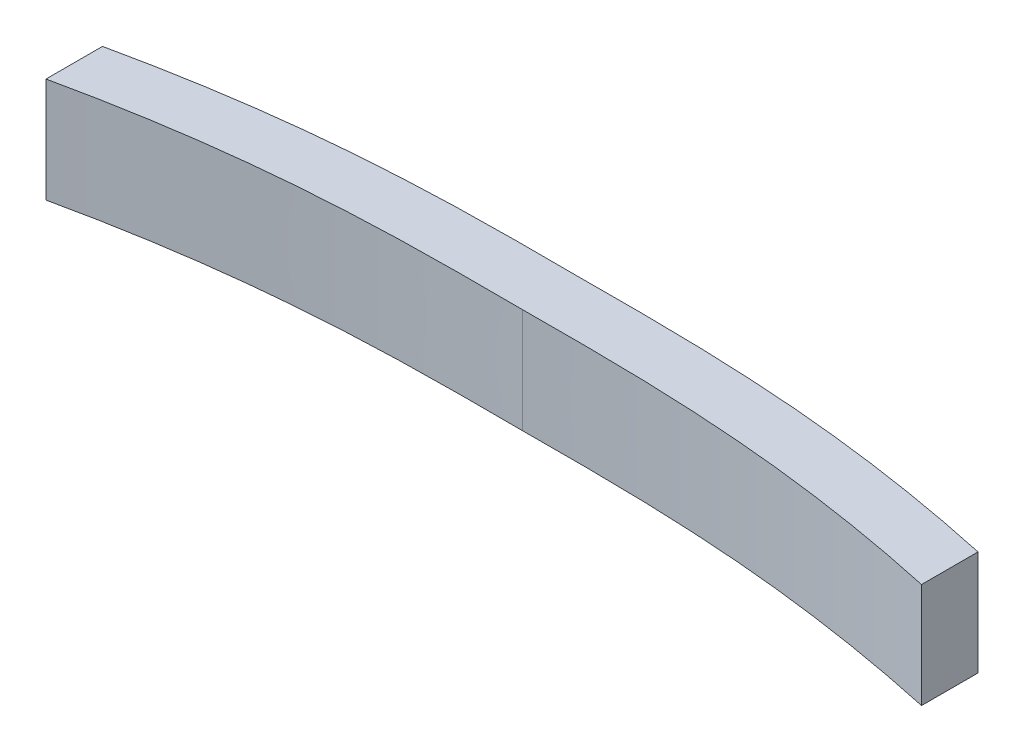
from build123d import *

# Parameters (mm, degrees)
BOSS_EXTRUDE1_DEPTH     = 14
CUT_EXTRUDE1_START      = -1
CUT_EXTRUDE1_DEPTH      = 12
SKETCH5_R               = 2
CUT_EXTRUDE2_DEPTH      = 10
SKETCH6_W               = 117.319125092
SKETCH6_H               = 10.762389646
CUT_EXTRUDE3_DEPTH      = 61.267639965
CUT_EXTRUDE3_DEPTH_BACK = 61.267639965


with BuildPart() as part:
    # Sketch1 → Boss-Extrude1 (new body)
    with BuildSketch(Plane(origin=(0, 0, 0), x_dir=(1, 0, 0), z_dir=(0, 1, 0))):
        with BuildLine():
            Line((-56.7108806, 8.042770274), (-56.7108806, 6.805307476))
            Line((-56.7108806, 6.805307476), (-32.823491302, 6.805307476))
            add(Edge.make_bspline(
                [(-32.823491302, 6.805307476), (-32.296255898, 6.856181615), (-26.989208291, 7.346453988), (-16.87934757, 7.860332352), (-7.605819721, 7.844934175), (-2.44151388, 7.817702683)],
                knots=[0.442922252, 0.442922252, 0.442922252, 0.442922252, 0.47203113, 0.735860593, 1, 1, 1, 1], degree=3))
            add(Edge.make_bspline(
                [(27.940463543, 6.805307476), (27.413228139, 6.856181615), (22.106180532, 7.346453988), (11.99631981, 7.860332352), (2.722791962, 7.844934175), (-2.44151388, 7.817702683)],
                knots=[0.442922252, 0.442922252, 0.442922252, 0.442922252, 0.47203113, 0.735860593, 1, 1, 1, 1], degree=3))
            Line((27.940463543, 6.805307476), (51.827852841, 6.805307476))
            Line((51.827852841, 6.805307476), (51.827852841, 8.042770274))
            add(Edge.make_bspline(
                [(51.827852841, 8.042770274), (43.440678216, 9.870534091), (30.144344491, 11.93787877), (11.99631981, 12.860332352), (2.722791962, 12.844934175), (-2.44151388, 12.817702683)],
                knots=[0, 0, 0, 0, 0.47203113, 0.735860593, 1, 1, 1, 1], degree=3))
            add(Edge.make_bspline(
                [(-56.7108806, 8.042770274), (-48.323705975, 9.870534091), (-35.02737225, 11.93787877), (-16.87934757, 12.860332352), (-7.605819721, 12.844934175), (-2.44151388, 12.817702683)],
                knots=[0, 0, 0, 0, 0.47203113, 0.735860593, 1, 1, 1, 1], degree=3))
        make_face()
        with BuildLine():
            Line((-32.823491302, 6.805307476), (-56.7108806, 6.805307476))
            Line((-56.7108806, 6.805307476), (-56.7108806, 3.042770274))
            add(Edge.make_bspline(
                [(-56.7108806, 3.042770274), (-48.840920262, 4.757820859), (-40.845933501, 6.031203848), (-32.823491302, 6.805307476)],
                knots=[0, 0, 0, 0, 0.442922252, 0.442922252, 0.442922252, 0.442922252], degree=3))
        make_face()
        with BuildLine():
            Line((-56.7108806, 10.042770274), (-56.7108806, 8.042770274))
            add(Edge.make_bspline(
                [(-56.7108806, 8.042770274), (-48.323705975, 9.870534091), (-35.02737225, 11.93787877), (-16.87934757, 12.860332352), (-7.605819721, 12.844934175), (-2.44151388, 12.817702683)],
                knots=[0, 0, 0, 0, 0.47203113, 0.735860593, 1, 1, 1, 1], degree=3))
            add(Edge.make_bspline(
                [(51.827852841, 8.042770274), (43.440678216, 9.870534091), (30.144344491, 11.93787877), (11.99631981, 12.860332352), (2.722791962, 12.844934175), (-2.44151388, 12.817702683)],
                knots=[0, 0, 0, 0, 0.47203113, 0.735860593, 1, 1, 1, 1], degree=3))
            Line((51.827852841, 8.042770274), (51.827852841, 10.042770274))
            add(Edge.make_bspline(
                [(51.827852841, 10.042770274), (43.440678216, 11.870534091), (30.144344491, 13.93787877), (11.99631981, 14.860332352), (2.722791962, 14.844934175), (-2.44151388, 14.817702683)],
                knots=[0, 0, 0, 0, 0.47203113, 0.735860593, 1, 1, 1, 1], degree=3))
            add(Edge.make_bspline(
                [(-56.7108806, 10.042770274), (-48.323705975, 11.870534091), (-35.02737225, 13.93787877), (-16.87934757, 14.860332352), (-7.605819721, 14.844934175), (-2.44151388, 14.817702683)],
                knots=[0, 0, 0, 0, 0.47203113, 0.735860593, 1, 1, 1, 1], degree=3))
        make_face()
        with BuildLine():
            Line((51.827852841, 6.805307476), (27.940463543, 6.805307476))
            add(Edge.make_bspline(
                [(51.827852841, 3.042770274), (43.957892503, 4.757820859), (35.962905742, 6.031203848), (27.940463543, 6.805307476)],
                knots=[0, 0, 0, 0, 0.442922252, 0.442922252, 0.442922252, 0.442922252], degree=3))
            Line((51.827852841, 3.042770274), (51.827852841, 6.805307476))
        make_face()
    extrude(amount=BOSS_EXTRUDE1_DEPTH)

    # Sketch2 → Cut-Extrude1 (cut)
    with BuildSketch(Plane(origin=(0, 14, 0), x_dir=(1, 0, 0), z_dir=(0, 1, 0)).offset(CUT_EXTRUDE1_START)):
        with BuildLine():
            Line((-55.7108806, 10.258170898), (-55.7108806, 4.258086623))
            add(Edge.make_bspline(
                [(-55.7108806, 4.258086623), (-50.342859001, 5.400468361), (-41.88238795, 6.862517021), (-30.478251076, 8.08618105), (-21.960755969, 8.606039162), (-12.680255084, 8.866102662), (-2.488255396, 8.788816201), (7.839601208, 8.866738732), (17.143204354, 8.604590131), (25.594666904, 8.081695492), (36.910484771, 6.875367198), (45.349986498, 5.423872017), (50.827852841, 4.258091684)],
                knots=[0.009365711, 0.009365711, 0.009365711, 0.009365711, 0.160113822, 0.245011966, 0.32430349, 0.394459254, 0.499999871, 0.60425614, 0.678146052, 0.755618705, 0.836798939, 0.990634118, 0.990634118, 0.990634118, 0.990634118], degree=3))
            Line((50.827852841, 4.258091684), (50.827852841, 10.258170898))
            add(Edge.make_bspline(
                [(50.827852841, 10.258170898), (42.763137338, 11.97497257), (29.804113131, 13.955172533), (11.99631981, 14.860332352), (2.722791962, 14.844934175), (-2.44151388, 14.817702683)],
                knots=[0.01874757, 0.01874757, 0.01874757, 0.01874757, 0.47203113, 0.735860593, 1, 1, 1, 1], degree=3))
            add(Edge.make_bspline(
                [(-2.44151388, 14.817702683), (-7.605819721, 14.844934175), (-16.87934757, 14.860332352), (-34.68714089, 13.955172533), (-47.646165097, 11.97497257), (-55.7108806, 10.258170898)],
                knots=[0, 0, 0, 0, 0.264139407, 0.52796887, 0.98125243, 0.98125243, 0.98125243, 0.98125243], degree=3))
        make_face()
        with BuildLine():
            Line((-2.44151388, 17.910861514), (-2.44151388, 14.817702683))
            add(Edge.make_bspline(
                [(50.827852841, 10.258170898), (42.763137338, 11.97497257), (29.804113131, 13.955172533), (11.99631981, 14.860332352), (2.722791962, 14.844934175), (-2.44151388, 14.817702683)],
                knots=[0.01874757, 0.01874757, 0.01874757, 0.01874757, 0.47203113, 0.735860593, 1, 1, 1, 1], degree=3))
            Line((50.827852841, 10.258170898), (50.827852841, 19.353755181))
            Line((50.827852841, 19.353755181), (-2.44151388, 17.910861514))
        make_face()
        with BuildLine():
            Line((-55.7108806, 16.467967847), (-55.7108806, 10.258170898))
            add(Edge.make_bspline(
                [(-2.44151388, 14.817702683), (-7.605819721, 14.844934175), (-16.87934757, 14.860332352), (-34.68714089, 13.955172533), (-47.646165097, 11.97497257), (-55.7108806, 10.258170898)],
                knots=[0, 0, 0, 0, 0.264139407, 0.52796887, 0.98125243, 0.98125243, 0.98125243, 0.98125243], degree=3))
            Line((-2.44151388, 14.817702683), (-2.44151388, 17.910861514))
            Line((-2.44151388, 17.910861514), (-55.7108806, 16.467967847))
        make_face()
    extrude(amount=-CUT_EXTRUDE1_DEPTH, mode=Mode.SUBTRACT)

    # Sketch5 → Cut-Extrude2 (cut)
    with BuildSketch(Plane(origin=(0, 1, 0), x_dir=(1, 0, 0), z_dir=(0, 1, 0))):
        with Locations((-2.44151388, 14.817702683)):
            Circle(SKETCH5_R)
    extrude(amount=-CUT_EXTRUDE2_DEPTH, mode=Mode.SUBTRACT)

    # Sketch6 → Cut-Extrude3 (cut, two sides)
    with BuildSketch(Plane.XY) as cut_extrude3_sk:
        with Locations((-0.730172647, -4.381194823)):
            Rectangle(SKETCH6_W, SKETCH6_H)
    extrude(amount=CUT_EXTRUDE3_DEPTH, mode=Mode.SUBTRACT)
    extrude(cut_extrude3_sk.sketch, amount=-CUT_EXTRUDE3_DEPTH_BACK, mode=Mode.SUBTRACT)


solid = part.part
